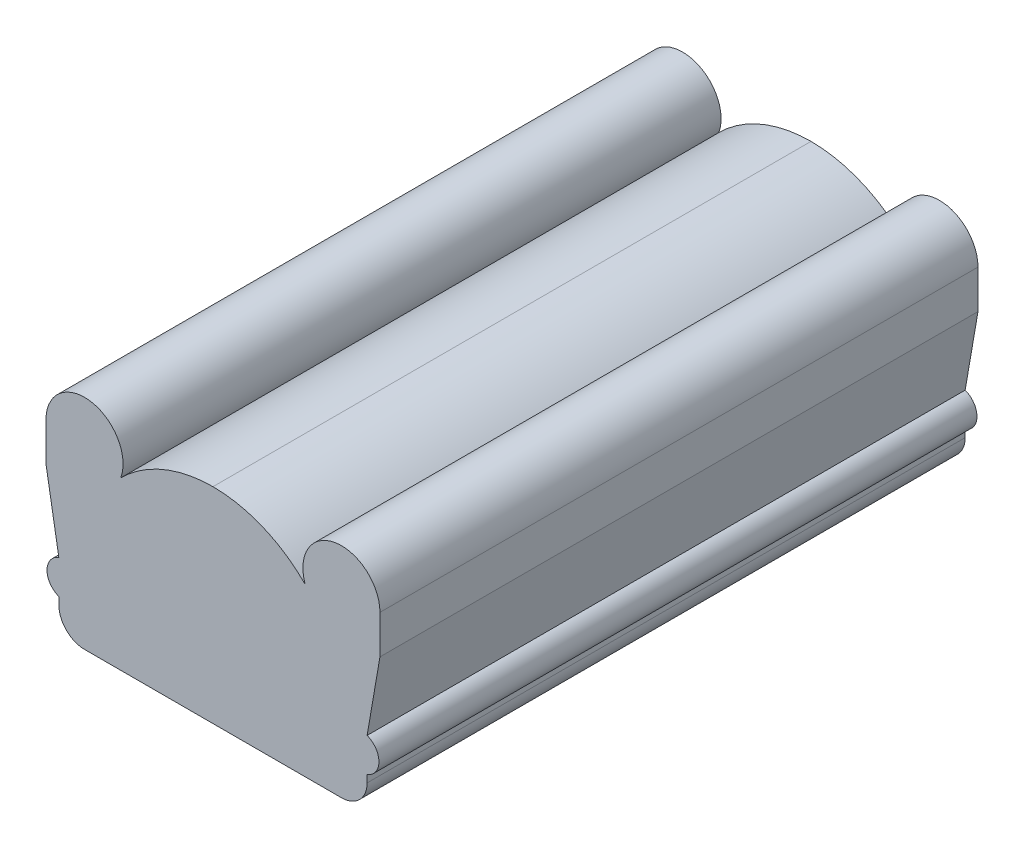
from build123d import *

# Parameters (mm, degrees)
BOSS_EXTRUDE1_DEPTH = 295.656
FILLET1_R           = 12.7


with BuildPart() as part:
    # Sketch1 → Boss-Extrude1 (new body)
    with BuildSketch(Plane.XY):
        with BuildLine():
            Line((82.55, 88.9), (82.55, 69.85))
            Line((82.55, 69.85), (76.2, 33.02))
            ThreePointArc((76.2, 33.02), (82.042, 24.668844631), (76.2, 16.317689262))
            Line((76.2, 16.317689262), (76.2, 0))
            Line((76.2, 0), (-76.2, 0))
            Line((-76.2, 0), (-76.2, 16.317689262))
            ThreePointArc((-76.2, 16.317689262), (-82.042, 24.668844631), (-76.2, 33.02))
            Line((-76.2, 33.02), (-82.55, 69.85))
            Line((-82.55, 69.85), (-82.55, 88.9))
            ThreePointArc((-82.55, 88.9), (-60.192002215, 107.660587695), (-45.598855574, 82.38451627))
            ThreePointArc((-45.598855574, 82.38451627), (-24.696659186, 96.450806586), (0, 101.43451627))
            ThreePointArc((0, 101.43451627), (24.696659186, 96.450806586), (45.598855574, 82.38451627))
            ThreePointArc((45.598855574, 82.38451627), (60.192002215, 107.660587695), (82.55, 88.9))
        make_face()
    extrude(amount=BOSS_EXTRUDE1_DEPTH)

    # Fillet1
    fillet1_edges = [part.edges().sort_by_distance(p)[0] for p in [
        (76.2, 0, 147.828),
        (-76.2, 0, 147.828),
    ]]
    fillet(fillet1_edges, radius=FILLET1_R)


solid = part.part
